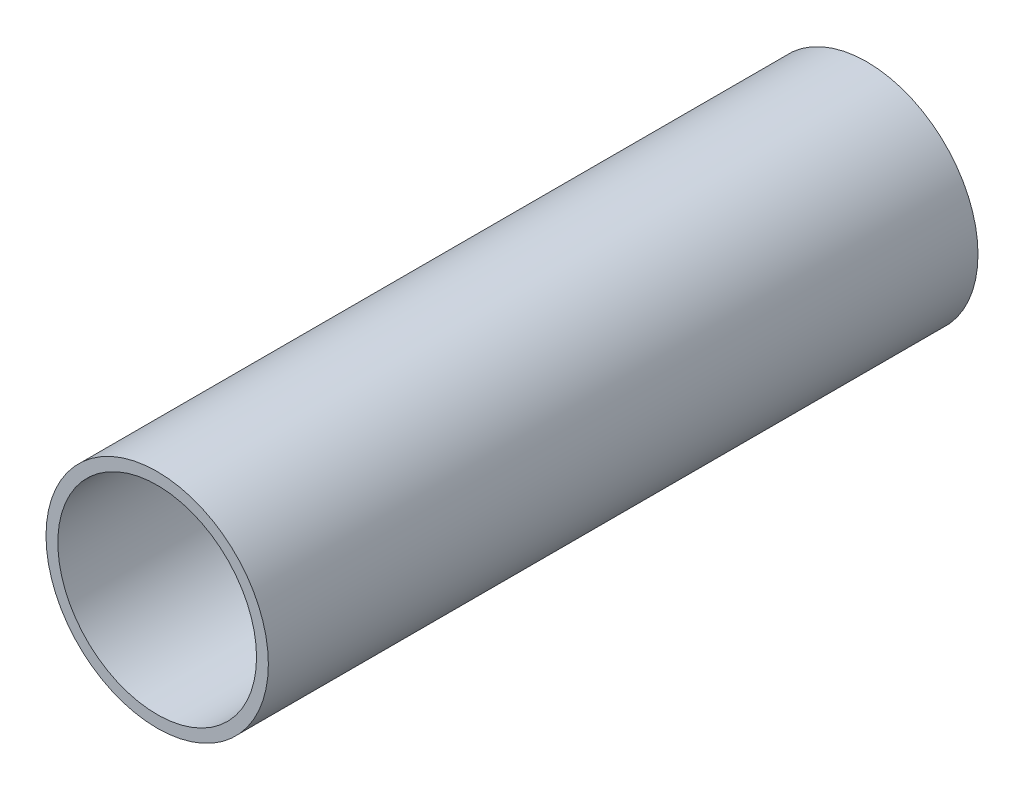
from build123d import *

# Parameters (mm, degrees)
SKETCH1_R           = 5.969
BOSS_EXTRUDE1_DEPTH = 38.1
SKETCH2_R           = 5.334
CUT_EXTRUDE1_DEPTH  = 38.1


with BuildPart() as part:
    # Sketch1 → Boss-Extrude1 (new body)
    with BuildSketch(Plane.XY):
        Circle(SKETCH1_R)
    extrude(amount=BOSS_EXTRUDE1_DEPTH)

    # Sketch2 → Cut-Extrude1 (cut)
    with BuildSketch(Plane.XY.offset(38.1)):
        Circle(SKETCH2_R)
    extrude(amount=-CUT_EXTRUDE1_DEPTH, mode=Mode.SUBTRACT)


solid = part.part
